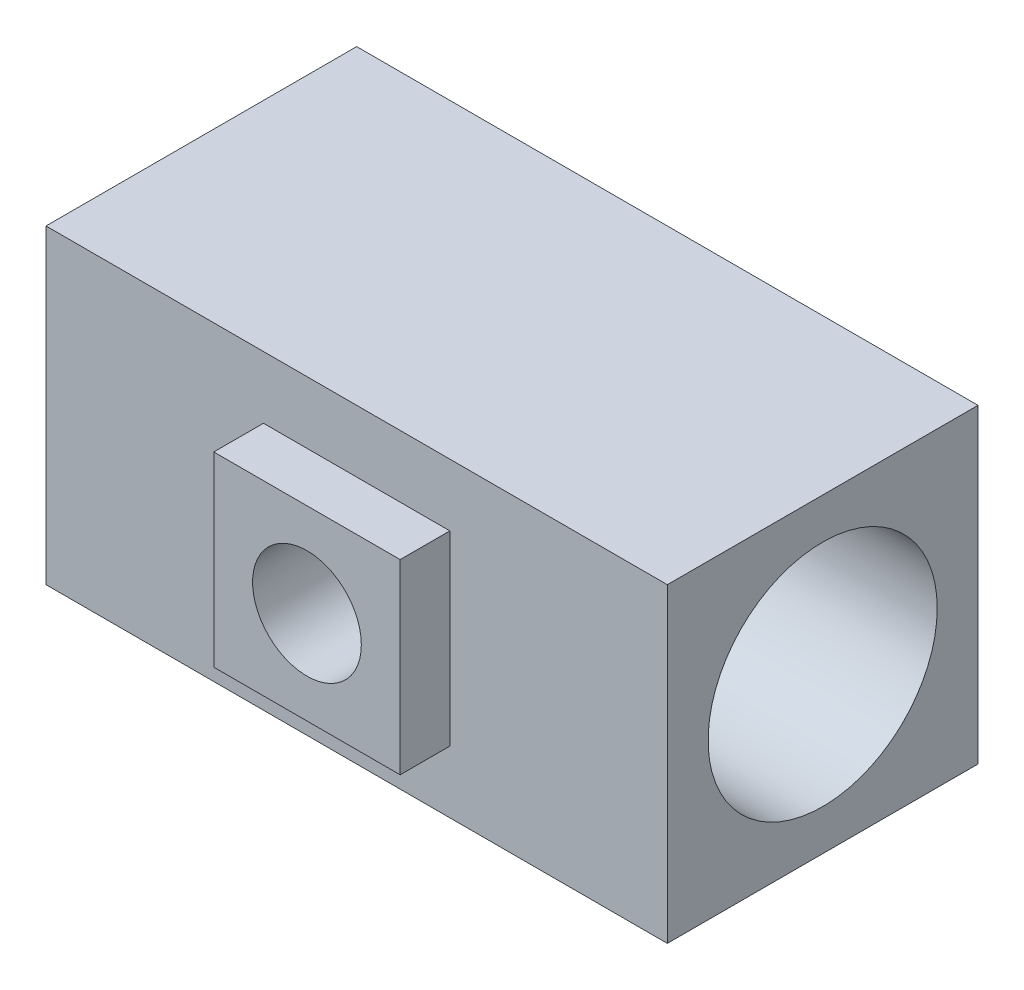
from build123d import *

# Parameters (mm, degrees)
SKETCH2_W                          = 63.5
SKETCH2_H                          = 31.75
BOSS_EXTRUDE1_DEPTH                = 31.75
F_59_64_0_92188_DIAMETER_HOLE1_D   = 23.415752
BOSS_EXTRUDE2_DEPTH                = 5.08
F_7_16_0_4375_DIAMETER_HOLE1_D     = 11.1125
F_7_16_0_4375_DIAMETER_HOLE1_DEPTH = 25.4
F_7_16_0_4375_DIAMETER_HOLE1_TIP   = 3.338531814


with BuildPart() as part:
    # Sketch2 → Boss-Extrude1 (new body)
    with BuildSketch(Plane(origin=(0, 0, 0), x_dir=(1, 0, 0), z_dir=(0, 1, 0))):
        Rectangle(SKETCH2_W, SKETCH2_H)
    extrude(amount=BOSS_EXTRUDE1_DEPTH)

    # 59/64 (0.92188) Diameter Hole1 (through all)
    with Locations(Plane(origin=(31.75, 0, 0), x_dir=(0, 0, -1), z_dir=(1, 0, 0))):
        with Locations((0, 15.875)):
            Hole(F_59_64_0_92188_DIAMETER_HOLE1_D / 2)

    # Sketch10 → Boss-Extrude2 (add)
    with BuildSketch(Plane.XY.offset(15.875)):
        Polygon((9.525, 11.1125), (-9.525, 20.6375), (-9.525, 6.35), (9.525, 6.35), align=None)
        Polygon((-9.525, 25.4), (-9.525, 20.6375), (9.525, 11.1125), (9.525, 25.4), align=None)
    extrude(amount=BOSS_EXTRUDE2_DEPTH)

    # 7/16 (0.4375) Diameter Hole1
    with Locations(Plane.XY.offset(20.955)):
        with Locations((0, 15.875)):
            Hole(F_7_16_0_4375_DIAMETER_HOLE1_D / 2, depth=F_7_16_0_4375_DIAMETER_HOLE1_DEPTH)
            with Locations((0, 0, -(F_7_16_0_4375_DIAMETER_HOLE1_DEPTH + F_7_16_0_4375_DIAMETER_HOLE1_TIP / 2))):  # 118° drill point
                Cone(0, F_7_16_0_4375_DIAMETER_HOLE1_D / 2, F_7_16_0_4375_DIAMETER_HOLE1_TIP, mode=Mode.SUBTRACT)


solid = part.part
